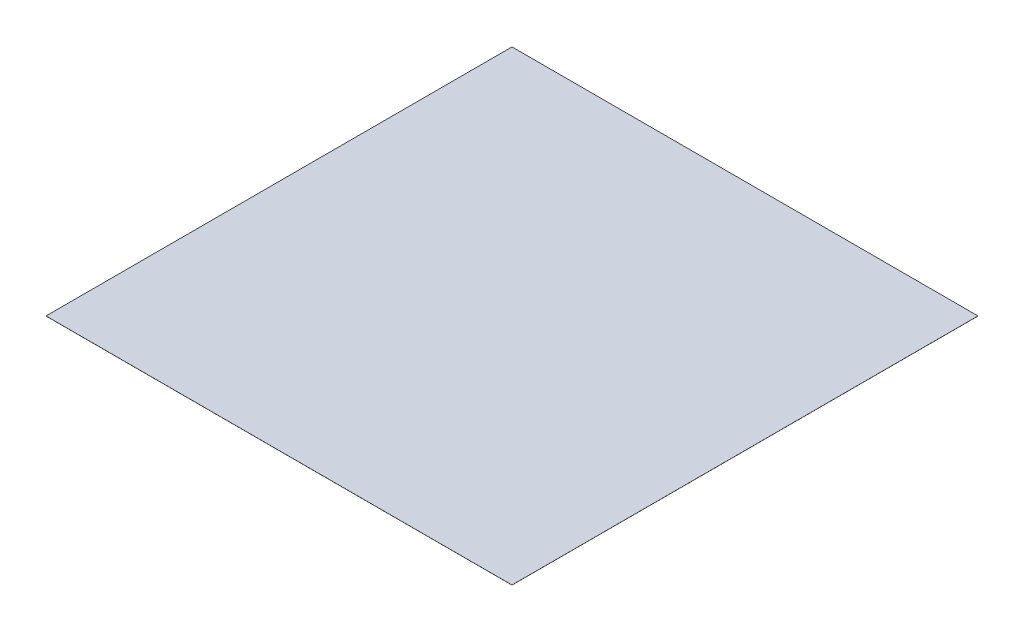
from build123d import *

# Parameters (mm, degrees)
SKETCH1_W           = 50000
SKETCH1_H           = 50000
BOSS_EXTRUDE1_DEPTH = 10


with BuildPart() as part:
    # Sketch1 → Boss-Extrude1 (new body)
    with BuildSketch(Plane(origin=(0, 0, 0), x_dir=(1, 0, 0), z_dir=(0, 1, 0))):
        with Locations((25000, 25000)):
            Rectangle(SKETCH1_W, SKETCH1_H)
    extrude(amount=BOSS_EXTRUDE1_DEPTH)


solid = part.part
